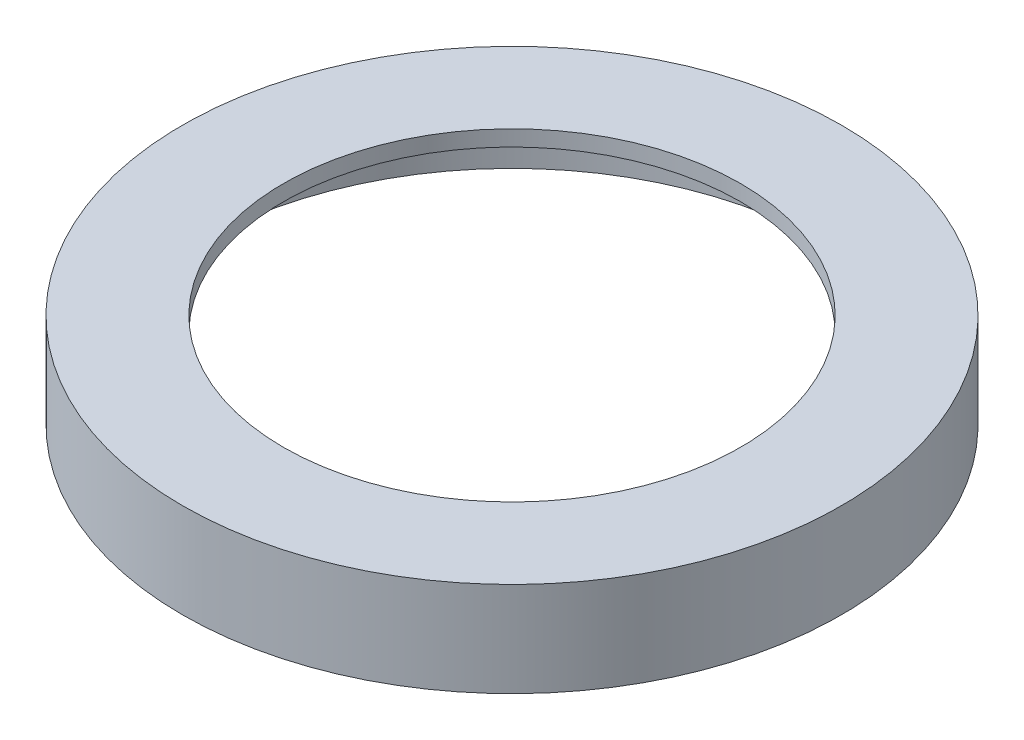
from build123d import *

# Parameters (mm, degrees)
SKETCH1_R           = 53.1114
SKETCH1_R_2         = 50.5714
BOSS_EXTRUDE1_DEPTH = 12.7
SKETCH2_R           = 53.1114
SKETCH2_R_2         = 36.83
BOSS_EXTRUDE2_DEPTH = 2.54


with BuildPart() as part:
    # Sketch1 → Boss-Extrude1 (new body)
    with BuildSketch(Plane(origin=(0, 0, 0), x_dir=(1, 0, 0), z_dir=(0, 1, 0))):
        Circle(SKETCH1_R)
        Circle(SKETCH1_R_2, mode=Mode.SUBTRACT)
    extrude(amount=BOSS_EXTRUDE1_DEPTH)

    # Sketch2 → Boss-Extrude2 (add)
    with BuildSketch(Plane(origin=(0, 12.7, 0), x_dir=(1, 0, 0), z_dir=(0, 1, 0))):
        Circle(SKETCH2_R)
        Circle(SKETCH2_R_2, mode=Mode.SUBTRACT)
    extrude(amount=BOSS_EXTRUDE2_DEPTH)


solid = part.part
